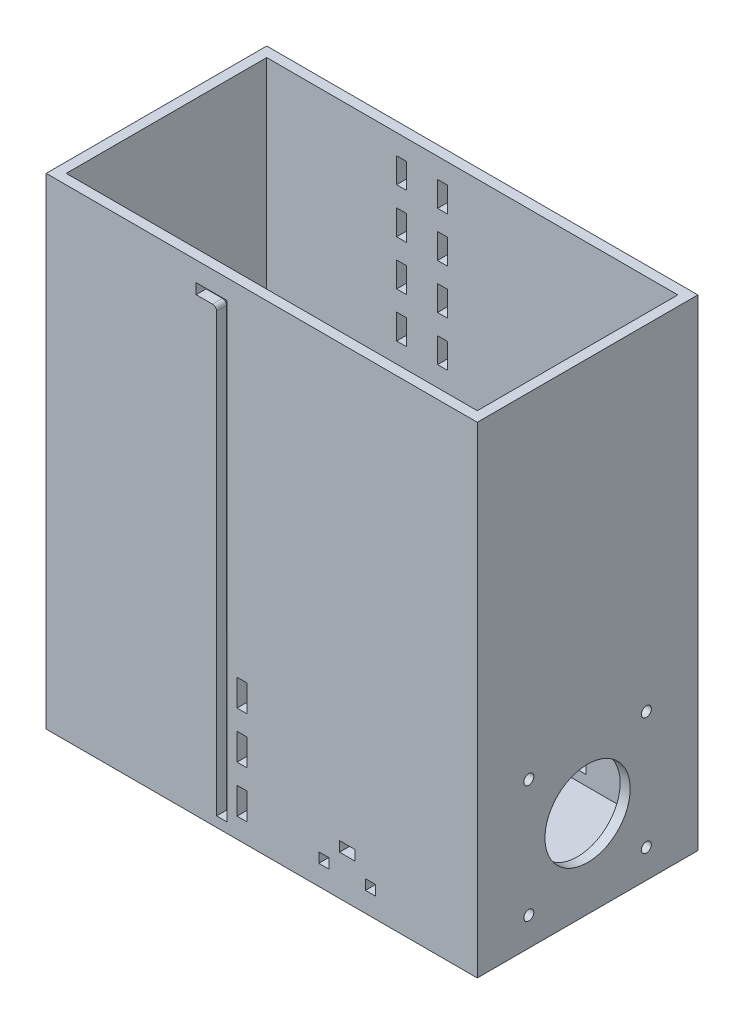
from build123d import *

# Parameters (mm, degrees)
SKETCH1_W              = 273.05
SKETCH1_H              = 139.7
BOSS_EXTRUDE1_DEPTH    = 6.35
SKETCH2_W              = 273.05
SKETCH2_H              = 139.7
SKETCH2_W_2            = 260.35
SKETCH2_H_2            = 127
BOSS_EXTRUDE2_DEPTH    = 298.45
SKETCH3_W              = 6.35
SKETCH3_H              = 16.933333333
SKETCH3_H_2            = 16.933333334
DOOR_SLOT_DEPTH        = 12.7
DOOR_GUIDE_HOLES_REACH = 361.617
SKETCH4_W              = 6.35
SKETCH4_H              = 15.875
LEVER_HOLES_W          = 9.652
LEVER_HOLES_H          = 6.35
LEVER_HOLES_W_2        = 6.35
CUT_EXTRUDE1_DEPTH     = 363.019620497
CUT_EXTRUDE2_REACH     = 417.137
SKETCH7_R              = 26.9875
CUT_EXTRUDE3_REACH     = 417.137
SKETCH8_R              = 3.175


with BuildPart() as part:
    # Sketch1 → Boss-Extrude1 (new body)
    with BuildSketch(Plane(origin=(0, 0, 0), x_dir=(1, 0, 0), z_dir=(0, 1, 0))):
        Rectangle(SKETCH1_W, SKETCH1_H)
    extrude(amount=BOSS_EXTRUDE1_DEPTH)

    # Sketch2 → Boss-Extrude2 (add)
    with BuildSketch(Plane(origin=(0, 6.35, 0), x_dir=(1, 0, 0), z_dir=(0, 1, 0))):
        Rectangle(SKETCH2_W, SKETCH2_H)
        Rectangle(SKETCH2_W_2, SKETCH2_H_2, mode=Mode.SUBTRACT)
    extrude(amount=BOSS_EXTRUDE2_DEPTH)

    # Sketch3 → Door Slot (cut)
    with BuildSketch(Plane.XY.offset(69.85)):
        with BuildLine():
            Line((-28.575, 283.21), (-28.575, 6.35))
            Line((-28.575, 6.35), (-21.971, 6.35))
            Line((-21.971, 6.35), (-21.971, 292.354))
            Line((-21.971, 292.354), (-41.529, 292.354))
            Line((-41.529, 292.354), (-41.529, 285.75))
            Line((-41.529, 285.75), (-31.115, 285.75))
            ThreePointArc((-31.115, 285.75), (-29.318948776, 285.006051224), (-28.575, 283.21))
        make_face()
        with Locations((-12.446, 80.433333334)):
            Rectangle(SKETCH3_W, SKETCH3_H)
        with Locations((-12.446, 50.8)):
            Rectangle(SKETCH3_W, SKETCH3_H_2)
        with Locations((-12.446, 21.166666667)):
            Rectangle(SKETCH3_W, SKETCH3_H)
    extrude(amount=-DOOR_SLOT_DEPTH, mode=Mode.SUBTRACT)

    # Sketch4 → Door Guide Holes (cut, up to next)
    with BuildSketch(Plane.XY.offset(-63.5), mode=Mode.PRIVATE) as door_guide_holes_sk1:
        with Locations((-44.704, 284.1625)):
            Rectangle(SKETCH4_W, SKETCH4_H)
    door_guide_holes_tool1 = extrude(door_guide_holes_sk1.sketch, amount=-DOOR_GUIDE_HOLES_REACH, mode=Mode.PRIVATE) & part.part
    # Sketch4 → Door Guide Holes (cut, up to next)
    with BuildSketch(Plane.XY.offset(-63.5), mode=Mode.PRIVATE) as door_guide_holes_sk2:
        with Locations((-44.704, 255.5875)):
            Rectangle(SKETCH4_W, SKETCH4_H)
    door_guide_holes_tool2 = extrude(door_guide_holes_sk2.sketch, amount=-DOOR_GUIDE_HOLES_REACH, mode=Mode.PRIVATE) & part.part
    # Sketch4 → Door Guide Holes (cut, up to next)
    with BuildSketch(Plane.XY.offset(-63.5), mode=Mode.PRIVATE) as door_guide_holes_sk3:
        with Locations((-44.704, 227.0125)):
            Rectangle(SKETCH4_W, SKETCH4_H)
    door_guide_holes_tool3 = extrude(door_guide_holes_sk3.sketch, amount=-DOOR_GUIDE_HOLES_REACH, mode=Mode.PRIVATE) & part.part
    # Sketch4 → Door Guide Holes (cut, up to next)
    with BuildSketch(Plane.XY.offset(-63.5), mode=Mode.PRIVATE) as door_guide_holes_sk4:
        with Locations((-44.704, 198.4375)):
            Rectangle(SKETCH4_W, SKETCH4_H)
    door_guide_holes_tool4 = extrude(door_guide_holes_sk4.sketch, amount=-DOOR_GUIDE_HOLES_REACH, mode=Mode.PRIVATE) & part.part
    # Sketch4 → Door Guide Holes (cut, up to next)
    with BuildSketch(Plane.XY.offset(-63.5), mode=Mode.PRIVATE) as door_guide_holes_sk5:
        with Locations((-44.704, 169.8625)):
            Rectangle(SKETCH4_W, SKETCH4_H)
    door_guide_holes_tool5 = extrude(door_guide_holes_sk5.sketch, amount=-DOOR_GUIDE_HOLES_REACH, mode=Mode.PRIVATE) & part.part
    # Sketch4 → Door Guide Holes (cut, up to next)
    with BuildSketch(Plane.XY.offset(-63.5), mode=Mode.PRIVATE) as door_guide_holes_sk6:
        with Locations((-44.704, 141.2875)):
            Rectangle(SKETCH4_W, SKETCH4_H)
    door_guide_holes_tool6 = extrude(door_guide_holes_sk6.sketch, amount=-DOOR_GUIDE_HOLES_REACH, mode=Mode.PRIVATE) & part.part
    # Sketch4 → Door Guide Holes (cut, up to next)
    with BuildSketch(Plane.XY.offset(-63.5), mode=Mode.PRIVATE) as door_guide_holes_sk7:
        with Locations((-44.704, 112.7125)):
            Rectangle(SKETCH4_W, SKETCH4_H)
    door_guide_holes_tool7 = extrude(door_guide_holes_sk7.sketch, amount=-DOOR_GUIDE_HOLES_REACH, mode=Mode.PRIVATE) & part.part
    # Sketch4 → Door Guide Holes (cut, up to next)
    with BuildSketch(Plane.XY.offset(-63.5), mode=Mode.PRIVATE) as door_guide_holes_sk8:
        with Locations((-44.704, 84.1375)):
            Rectangle(SKETCH4_W, SKETCH4_H)
    door_guide_holes_tool8 = extrude(door_guide_holes_sk8.sketch, amount=-DOOR_GUIDE_HOLES_REACH, mode=Mode.PRIVATE) & part.part
    # Sketch4 → Door Guide Holes (cut, up to next)
    with BuildSketch(Plane.XY.offset(-63.5), mode=Mode.PRIVATE) as door_guide_holes_sk9:
        with Locations((-44.704, 55.5625)):
            Rectangle(SKETCH4_W, SKETCH4_H)
    door_guide_holes_tool9 = extrude(door_guide_holes_sk9.sketch, amount=-DOOR_GUIDE_HOLES_REACH, mode=Mode.PRIVATE) & part.part
    # Sketch4 → Door Guide Holes (cut, up to next)
    with BuildSketch(Plane.XY.offset(-63.5), mode=Mode.PRIVATE) as door_guide_holes_sk10:
        with Locations((-44.704, 26.9875)):
            Rectangle(SKETCH4_W, SKETCH4_H)
    door_guide_holes_tool10 = extrude(door_guide_holes_sk10.sketch, amount=-DOOR_GUIDE_HOLES_REACH, mode=Mode.PRIVATE) & part.part
    door_guide_holes_1 = door_guide_holes_tool1.solids().sort_by_distance((-44.704, 284.1625, -63.5))[0]
    add(door_guide_holes_1, mode=Mode.SUBTRACT)
    door_guide_holes_2 = door_guide_holes_tool2.solids().sort_by_distance((-44.704, 255.5875, -63.5))[0]
    add(door_guide_holes_2, mode=Mode.SUBTRACT)
    door_guide_holes_3 = door_guide_holes_tool3.solids().sort_by_distance((-44.704, 227.0125, -63.5))[0]
    add(door_guide_holes_3, mode=Mode.SUBTRACT)
    door_guide_holes_4 = door_guide_holes_tool4.solids().sort_by_distance((-44.704, 198.4375, -63.5))[0]
    add(door_guide_holes_4, mode=Mode.SUBTRACT)
    door_guide_holes_5 = door_guide_holes_tool5.solids().sort_by_distance((-44.704, 169.8625, -63.5))[0]
    add(door_guide_holes_5, mode=Mode.SUBTRACT)
    door_guide_holes_6 = door_guide_holes_tool6.solids().sort_by_distance((-44.704, 141.2875, -63.5))[0]
    add(door_guide_holes_6, mode=Mode.SUBTRACT)
    door_guide_holes_7 = door_guide_holes_tool7.solids().sort_by_distance((-44.704, 112.7125, -63.5))[0]
    add(door_guide_holes_7, mode=Mode.SUBTRACT)
    door_guide_holes_8 = door_guide_holes_tool8.solids().sort_by_distance((-44.704, 84.1375, -63.5))[0]
    add(door_guide_holes_8, mode=Mode.SUBTRACT)
    door_guide_holes_9 = door_guide_holes_tool9.solids().sort_by_distance((-44.704, 55.5625, -63.5))[0]
    add(door_guide_holes_9, mode=Mode.SUBTRACT)
    door_guide_holes_10 = door_guide_holes_tool10.solids().sort_by_distance((-44.704, 26.9875, -63.5))[0]
    add(door_guide_holes_10, mode=Mode.SUBTRACT)
    door_guide_holes = door_guide_holes_1 + door_guide_holes_2 + door_guide_holes_3 + door_guide_holes_4 + door_guide_holes_5 + door_guide_holes_6 + door_guide_holes_7 + door_guide_holes_8 + door_guide_holes_9 + door_guide_holes_10  # Door Guide Holes as one shape, for the pattern or mirror that repeats it

    # Mirror1: Door Guide Holes across plane
    add(door_guide_holes.mirror(Plane.ZY.offset(31.75)), mode=Mode.SUBTRACT)

    # Lever Holes → Cut-Extrude1 (cut, through all)
    with BuildSketch(Plane.XY.offset(69.85)):
        with Locations((54.102, 28.575)):
            Rectangle(LEVER_HOLES_W, LEVER_HOLES_H)
        with Locations((39.3065, 15.875)):
            Rectangle(LEVER_HOLES_W_2, LEVER_HOLES_H)
        with Locations((68.8975, 15.875)):
            Rectangle(LEVER_HOLES_W_2, LEVER_HOLES_H)
    extrude(amount=-CUT_EXTRUDE1_DEPTH, mode=Mode.SUBTRACT)

    # Sketch7 → Cut-Extrude2 (cut, up to next)
    with BuildSketch(Plane(origin=(136.525, 0, 0), x_dir=(0, 0, -1), z_dir=(1, 0, 0)), mode=Mode.PRIVATE) as cut_extrude2_sk1:
        with Locations((0, 55.372)):
            Circle(SKETCH7_R)
    cut_extrude2_tool1 = extrude(cut_extrude2_sk1.sketch, amount=-CUT_EXTRUDE2_REACH, mode=Mode.PRIVATE) & part.part
    # Sketch7 → Cut-Extrude2 (cut, up to next)
    with BuildSketch(Plane(origin=(136.525, 0, 0), x_dir=(0, 0, -1), z_dir=(1, 0, 0)), mode=Mode.PRIVATE) as cut_extrude2_sk2:
        with BuildLine():
            Line((-37.211, 89.408), (-37.211, 92.583))
            Line((-37.211, 92.583), (-34.036, 92.583))
            ThreePointArc((-34.036, 92.583), (-39.45606403, 94.82806403), (-37.211, 89.408))
        make_face()
    cut_extrude2_tool2 = extrude(cut_extrude2_sk2.sketch, amount=-CUT_EXTRUDE2_REACH, mode=Mode.PRIVATE) & part.part
    # Sketch7 → Cut-Extrude2 (cut, up to next)
    with BuildSketch(Plane(origin=(136.525, 0, 0), x_dir=(0, 0, -1), z_dir=(1, 0, 0)), mode=Mode.PRIVATE) as cut_extrude2_sk3:
        with BuildLine():
            Line((-34.036, 92.583), (-37.211, 92.583))
            Line((-37.211, 92.583), (-37.211, 89.408))
            ThreePointArc((-37.211, 89.408), (-34.96593597, 90.33793597), (-34.036, 92.583))
        make_face()
    cut_extrude2_tool3 = extrude(cut_extrude2_sk3.sketch, amount=-CUT_EXTRUDE2_REACH, mode=Mode.PRIVATE) & part.part
    # Sketch7 → Cut-Extrude2 (cut, up to next)
    with BuildSketch(Plane(origin=(136.525, 0, 0), x_dir=(0, 0, -1), z_dir=(1, 0, 0)), mode=Mode.PRIVATE) as cut_extrude2_sk4:
        with BuildLine():
            Line((-37.211, 89.408), (-37.211, 92.583))
            Line((-37.211, 92.583), (-34.036, 92.583))
            ThreePointArc((-34.036, 92.583), (-39.45606403, 94.82806403), (-37.211, 89.408))
        make_face()
    cut_extrude2_tool4 = extrude(cut_extrude2_sk4.sketch, amount=-CUT_EXTRUDE2_REACH, mode=Mode.PRIVATE) & part.part
    # Sketch7 → Cut-Extrude2 (cut, up to next)
    with BuildSketch(Plane(origin=(136.525, 0, 0), x_dir=(0, 0, -1), z_dir=(1, 0, 0)), mode=Mode.PRIVATE) as cut_extrude2_sk5:
        with BuildLine():
            Line((-34.036, 92.583), (-37.211, 92.583))
            Line((-37.211, 92.583), (-37.211, 89.408))
            ThreePointArc((-37.211, 89.408), (-34.96593597, 90.33793597), (-34.036, 92.583))
        make_face()
    cut_extrude2_tool5 = extrude(cut_extrude2_sk5.sketch, amount=-CUT_EXTRUDE2_REACH, mode=Mode.PRIVATE) & part.part
    # Sketch7 → Cut-Extrude2 (cut, up to next)
    with BuildSketch(Plane(origin=(136.525, 0, 0), x_dir=(0, 0, -1), z_dir=(1, 0, 0)), mode=Mode.PRIVATE) as cut_extrude2_sk6:
        with BuildLine():
            ThreePointArc((40.386, 92.583), (37.211, 95.758), (34.036, 92.583))
            Line((34.036, 92.583), (37.211, 92.583))
            Line((37.211, 92.583), (37.211, 89.408))
            ThreePointArc((37.211, 89.408), (39.45606403, 90.33793597), (40.386, 92.583))
        make_face()
    cut_extrude2_tool6 = extrude(cut_extrude2_sk6.sketch, amount=-CUT_EXTRUDE2_REACH, mode=Mode.PRIVATE) & part.part
    # Sketch7 → Cut-Extrude2 (cut, up to next)
    with BuildSketch(Plane(origin=(136.525, 0, 0), x_dir=(0, 0, -1), z_dir=(1, 0, 0)), mode=Mode.PRIVATE) as cut_extrude2_sk7:
        with BuildLine():
            Line((37.211, 92.583), (34.036, 92.583))
            ThreePointArc((34.036, 92.583), (34.96593597, 90.33793597), (37.211, 89.408))
            Line((37.211, 89.408), (37.211, 92.583))
        make_face()
    cut_extrude2_tool7 = extrude(cut_extrude2_sk7.sketch, amount=-CUT_EXTRUDE2_REACH, mode=Mode.PRIVATE) & part.part
    # Sketch7 → Cut-Extrude2 (cut, up to next)
    with BuildSketch(Plane(origin=(136.525, 0, 0), x_dir=(0, 0, -1), z_dir=(1, 0, 0)), mode=Mode.PRIVATE) as cut_extrude2_sk8:
        with BuildLine():
            ThreePointArc((40.386, 92.583), (37.211, 95.758), (34.036, 92.583))
            Line((34.036, 92.583), (37.211, 92.583))
            Line((37.211, 92.583), (37.211, 89.408))
            ThreePointArc((37.211, 89.408), (39.45606403, 90.33793597), (40.386, 92.583))
        make_face()
    cut_extrude2_tool8 = extrude(cut_extrude2_sk8.sketch, amount=-CUT_EXTRUDE2_REACH, mode=Mode.PRIVATE) & part.part
    # Sketch7 → Cut-Extrude2 (cut, up to next)
    with BuildSketch(Plane(origin=(136.525, 0, 0), x_dir=(0, 0, -1), z_dir=(1, 0, 0)), mode=Mode.PRIVATE) as cut_extrude2_sk9:
        with BuildLine():
            Line((37.211, 92.583), (34.036, 92.583))
            ThreePointArc((34.036, 92.583), (34.96593597, 90.33793597), (37.211, 89.408))
            Line((37.211, 89.408), (37.211, 92.583))
        make_face()
    cut_extrude2_tool9 = extrude(cut_extrude2_sk9.sketch, amount=-CUT_EXTRUDE2_REACH, mode=Mode.PRIVATE) & part.part
    # Sketch7 → Cut-Extrude2 (cut, up to next)
    with BuildSketch(Plane(origin=(136.525, 0, 0), x_dir=(0, 0, -1), z_dir=(1, 0, 0)), mode=Mode.PRIVATE) as cut_extrude2_sk10:
        with BuildLine():
            ThreePointArc((-34.036, 18.161), (-34.96593597, 20.40606403), (-37.211, 21.336))
            Line((-37.211, 21.336), (-37.211, 18.161))
            Line((-37.211, 18.161), (-34.036, 18.161))
        make_face()
    cut_extrude2_tool10 = extrude(cut_extrude2_sk10.sketch, amount=-CUT_EXTRUDE2_REACH, mode=Mode.PRIVATE) & part.part
    # Sketch7 → Cut-Extrude2 (cut, up to next)
    with BuildSketch(Plane(origin=(136.525, 0, 0), x_dir=(0, 0, -1), z_dir=(1, 0, 0)), mode=Mode.PRIVATE) as cut_extrude2_sk11:
        with BuildLine():
            Line((-37.211, 18.161), (-37.211, 21.336))
            ThreePointArc((-37.211, 21.336), (-39.45606403, 15.91593597), (-34.036, 18.161))
            Line((-34.036, 18.161), (-37.211, 18.161))
        make_face()
    cut_extrude2_tool11 = extrude(cut_extrude2_sk11.sketch, amount=-CUT_EXTRUDE2_REACH, mode=Mode.PRIVATE) & part.part
    # Sketch7 → Cut-Extrude2 (cut, up to next)
    with BuildSketch(Plane(origin=(136.525, 0, 0), x_dir=(0, 0, -1), z_dir=(1, 0, 0)), mode=Mode.PRIVATE) as cut_extrude2_sk12:
        with BuildLine():
            ThreePointArc((-34.036, 18.161), (-34.96593597, 20.40606403), (-37.211, 21.336))
            Line((-37.211, 21.336), (-37.211, 18.161))
            Line((-37.211, 18.161), (-34.036, 18.161))
        make_face()
    cut_extrude2_tool12 = extrude(cut_extrude2_sk12.sketch, amount=-CUT_EXTRUDE2_REACH, mode=Mode.PRIVATE) & part.part
    # Sketch7 → Cut-Extrude2 (cut, up to next)
    with BuildSketch(Plane(origin=(136.525, 0, 0), x_dir=(0, 0, -1), z_dir=(1, 0, 0)), mode=Mode.PRIVATE) as cut_extrude2_sk13:
        with BuildLine():
            Line((-37.211, 18.161), (-37.211, 21.336))
            ThreePointArc((-37.211, 21.336), (-39.45606403, 15.91593597), (-34.036, 18.161))
            Line((-34.036, 18.161), (-37.211, 18.161))
        make_face()
    cut_extrude2_tool13 = extrude(cut_extrude2_sk13.sketch, amount=-CUT_EXTRUDE2_REACH, mode=Mode.PRIVATE) & part.part
    # Sketch7 → Cut-Extrude2 (cut, up to next)
    with BuildSketch(Plane(origin=(136.525, 0, 0), x_dir=(0, 0, -1), z_dir=(1, 0, 0)), mode=Mode.PRIVATE) as cut_extrude2_sk14:
        with BuildLine():
            ThreePointArc((40.386, 18.161), (39.45606403, 20.40606403), (37.211, 21.336))
            Line((37.211, 21.336), (37.211, 18.161))
            Line((37.211, 18.161), (34.036, 18.161))
            ThreePointArc((34.036, 18.161), (37.211, 14.986), (40.386, 18.161))
        make_face()
    cut_extrude2_tool14 = extrude(cut_extrude2_sk14.sketch, amount=-CUT_EXTRUDE2_REACH, mode=Mode.PRIVATE) & part.part
    # Sketch7 → Cut-Extrude2 (cut, up to next)
    with BuildSketch(Plane(origin=(136.525, 0, 0), x_dir=(0, 0, -1), z_dir=(1, 0, 0)), mode=Mode.PRIVATE) as cut_extrude2_sk15:
        with BuildLine():
            Line((37.211, 18.161), (37.211, 21.336))
            ThreePointArc((37.211, 21.336), (34.96593597, 20.40606403), (34.036, 18.161))
            Line((34.036, 18.161), (37.211, 18.161))
        make_face()
    cut_extrude2_tool15 = extrude(cut_extrude2_sk15.sketch, amount=-CUT_EXTRUDE2_REACH, mode=Mode.PRIVATE) & part.part
    # Sketch7 → Cut-Extrude2 (cut, up to next)
    with BuildSketch(Plane(origin=(136.525, 0, 0), x_dir=(0, 0, -1), z_dir=(1, 0, 0)), mode=Mode.PRIVATE) as cut_extrude2_sk16:
        with BuildLine():
            ThreePointArc((40.386, 18.161), (39.45606403, 20.40606403), (37.211, 21.336))
            Line((37.211, 21.336), (37.211, 18.161))
            Line((37.211, 18.161), (34.036, 18.161))
            ThreePointArc((34.036, 18.161), (37.211, 14.986), (40.386, 18.161))
        make_face()
    cut_extrude2_tool16 = extrude(cut_extrude2_sk16.sketch, amount=-CUT_EXTRUDE2_REACH, mode=Mode.PRIVATE) & part.part
    # Sketch7 → Cut-Extrude2 (cut, up to next)
    with BuildSketch(Plane(origin=(136.525, 0, 0), x_dir=(0, 0, -1), z_dir=(1, 0, 0)), mode=Mode.PRIVATE) as cut_extrude2_sk17:
        with BuildLine():
            Line((37.211, 18.161), (37.211, 21.336))
            ThreePointArc((37.211, 21.336), (34.96593597, 20.40606403), (34.036, 18.161))
            Line((34.036, 18.161), (37.211, 18.161))
        make_face()
    cut_extrude2_tool17 = extrude(cut_extrude2_sk17.sketch, amount=-CUT_EXTRUDE2_REACH, mode=Mode.PRIVATE) & part.part
    add(cut_extrude2_tool1.solids().sort_by_distance((136.525, 55.372, 0))[0], mode=Mode.SUBTRACT)
    add(cut_extrude2_tool2.solids().sort_by_distance((136.525, 93.032171, 37.660171))[0], mode=Mode.SUBTRACT)
    add(cut_extrude2_tool3.solids().sort_by_distance((136.525, 91.235488, 35.863488))[0], mode=Mode.SUBTRACT)
    add(cut_extrude2_tool4.solids().sort_by_distance((136.525, 93.032171, 37.660171))[0], mode=Mode.SUBTRACT)
    add(cut_extrude2_tool5.solids().sort_by_distance((136.525, 91.235488, 35.863488))[0], mode=Mode.SUBTRACT)
    add(cut_extrude2_tool6.solids().sort_by_distance((136.525, 93.032171, -37.660171))[0], mode=Mode.SUBTRACT)
    add(cut_extrude2_tool7.solids().sort_by_distance((136.525, 91.235488, -35.863488))[0], mode=Mode.SUBTRACT)
    add(cut_extrude2_tool8.solids().sort_by_distance((136.525, 93.032171, -37.660171))[0], mode=Mode.SUBTRACT)
    add(cut_extrude2_tool9.solids().sort_by_distance((136.525, 91.235488, -35.863488))[0], mode=Mode.SUBTRACT)
    add(cut_extrude2_tool10.solids().sort_by_distance((136.525, 19.508512, 35.863488))[0], mode=Mode.SUBTRACT)
    add(cut_extrude2_tool11.solids().sort_by_distance((136.525, 17.711829, 37.660171))[0], mode=Mode.SUBTRACT)
    add(cut_extrude2_tool12.solids().sort_by_distance((136.525, 19.508512, 35.863488))[0], mode=Mode.SUBTRACT)
    add(cut_extrude2_tool13.solids().sort_by_distance((136.525, 17.711829, 37.660171))[0], mode=Mode.SUBTRACT)
    add(cut_extrude2_tool14.solids().sort_by_distance((136.525, 17.711829, -37.660171))[0], mode=Mode.SUBTRACT)
    add(cut_extrude2_tool15.solids().sort_by_distance((136.525, 19.508512, -35.863488))[0], mode=Mode.SUBTRACT)
    add(cut_extrude2_tool16.solids().sort_by_distance((136.525, 17.711829, -37.660171))[0], mode=Mode.SUBTRACT)
    add(cut_extrude2_tool17.solids().sort_by_distance((136.525, 19.508512, -35.863488))[0], mode=Mode.SUBTRACT)

    # Sketch8 → Cut-Extrude3 (cut, up to next)
    with BuildSketch(Plane.ZY.offset(136.525), mode=Mode.PRIVATE) as cut_extrude3_sk1:
        with Locations((0, 19.05)):
            Circle(SKETCH8_R)
    cut_extrude3_tool1 = extrude(cut_extrude3_sk1.sketch, amount=-CUT_EXTRUDE3_REACH, mode=Mode.PRIVATE) & part.part
    add(cut_extrude3_tool1.solids().sort_by_distance((-136.525, 19.05, 0))[0], mode=Mode.SUBTRACT)


solid = part.part
